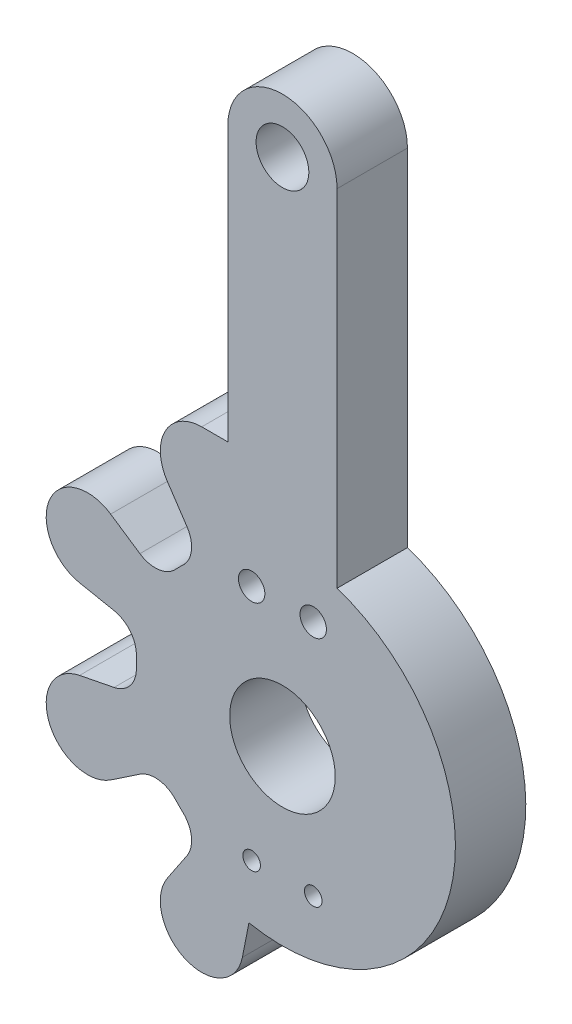
from build123d import *

# Parameters (mm, degrees)
SKETCH1_R           = 1.5
SKETCH1_R_2         = 3
SKETCH1_R_3         = 0.75
SKETCH1_R_4         = 0.5
BOSS_EXTRUDE1_DEPTH = 4


with BuildPart() as part:
    # Sketch1 → Boss-Extrude1 (new body)
    with BuildSketch(Plane.XY):
        with BuildLine():
            Line((16.530619317, 42.42561819), (16.530619317, 22.754982115))
            ThreePointArc((16.530619317, 22.754982115), (22.932240754, 10.915198881), (11.519776525, 3.779592091))
            Line((11.519776525, 3.779592091), (11.147094023, 1.893337277))
            ThreePointArc((11.147094023, 1.893337277), (11.123415667, 1.786594657), (11.094806165, 1.681066709))
            ThreePointArc((11.094806165, 1.681066709), (11.090483266, 1.666641986), (11.086068179, 1.652245212))
            ThreePointArc((11.086068179, 1.652245212), (7.936966432, 0.174837955), (6.754899921, 3.446273846))
            ThreePointArc((6.754899921, 3.446273846), (6.761958039, 3.45957584), (6.769101108, 3.47283241))
            ThreePointArc((6.769101108, 3.47283241), (6.823490663, 3.567681911), (6.882225966, 3.659903468))
            Line((6.882225966, 3.659903468), (7.995950227, 5.322085893))
            ThreePointArc((7.995950227, 5.322085893), (8.251124429, 6.376170558), (7.761765041, 7.344021653))
            ThreePointArc((7.761765041, 7.344021653), (7.549180699, 7.549179572), (7.344022782, 7.761763916))
            ThreePointArc((7.344022782, 7.761763916), (6.376171685, 8.251123307), (5.322087019, 7.995949102))
            Line((5.322087019, 7.995949102), (3.659904592, 6.882224839))
            ThreePointArc((3.659904592, 6.882224839), (3.567683036, 6.823489535), (3.472833536, 6.769099981))
            ThreePointArc((3.472833536, 6.769099981), (3.459576965, 6.761956912), (3.446274971, 6.754898794))
            ThreePointArc((3.446274971, 6.754898794), (0.174839081, 7.936965304), (1.652246338, 11.086067052))
            ThreePointArc((1.652246338, 11.086067052), (1.666643112, 11.090482139), (1.681067834, 11.094805038))
            ThreePointArc((1.681067834, 11.094805038), (1.786595783, 11.12341454), (1.893338403, 11.147092897))
            Line((1.893338403, 11.147092897), (3.856200846, 11.534911383))
            ThreePointArc((3.856200846, 11.534911383), (4.781986668, 12.099826389), (5.120331397, 13.130229803))
            ThreePointArc((5.120331397, 13.130229803), (5.115080125, 13.425618189), (5.120331401, 13.721006575))
            ThreePointArc((5.120331401, 13.721006575), (4.781986671, 14.751409991), (3.856200847, 15.316324996))
            Line((3.856200847, 15.316324996), (1.893338402, 15.704143481))
            ThreePointArc((1.893338402, 15.704143481), (1.786595783, 15.72782184), (1.681067835, 15.756431342))
            ThreePointArc((1.681067835, 15.756431342), (1.666643112, 15.760754241), (1.652246339, 15.765169327))
            ThreePointArc((1.652246339, 15.765169327), (0.174839082, 18.914271075), (3.446274972, 20.096337586))
            ThreePointArc((3.446274972, 20.096337586), (3.459576966, 20.089279467), (3.472833537, 20.082136399))
            ThreePointArc((3.472833537, 20.082136399), (3.567683038, 20.027746844), (3.659904595, 19.969011541))
            Line((3.659904595, 19.969011541), (5.322087019, 18.855287277))
            ThreePointArc((5.322087019, 18.855287277), (6.376171684, 18.600113075), (7.344022779, 19.089472463))
            ThreePointArc((7.344022779, 19.089472463), (7.549180698, 19.302056807), (7.761765042, 19.507214725))
            ThreePointArc((7.761765042, 19.507214725), (8.251124432, 20.475065821), (7.995950227, 21.529150485))
            Line((7.995950227, 21.529150485), (6.882225965, 23.191332912))
            ThreePointArc((6.882225965, 23.191332912), (6.823490661, 23.283554468), (6.769101106, 23.378403968))
            ThreePointArc((6.769101106, 23.378403968), (6.761958038, 23.391660539), (6.754899919, 23.404962533))
            ThreePointArc((6.754899919, 23.404962533), (6.822518946, 25.718097901), (8.837784858, 26.855582349))
            Line((8.837784858, 26.855582349), (10.320619317, 26.855582349))
            Line((10.320619317, 26.855582349), (10.320619317, 42.42561819))
            ThreePointArc((10.320619317, 42.42561819), (13.425619317, 45.53061819), (16.530619317, 42.42561819))
        make_face()
        with Locations((13.425619317, 42.42561819)):
            Circle(SKETCH1_R, mode=Mode.SUBTRACT)
        with Locations((13.425619317, 13.42561819)):
            Circle(SKETCH1_R_2, mode=Mode.SUBTRACT)
        with Locations((11.675619317, 20.42561819)):
            Circle(SKETCH1_R_3, mode=Mode.SUBTRACT)
        with Locations((15.175619317, 20.42561819)):
            Circle(SKETCH1_R_3, mode=Mode.SUBTRACT)
        with Locations((11.675619317, 6.92561819)):
            Circle(SKETCH1_R_4, mode=Mode.SUBTRACT)
        with Locations((15.175619317, 6.92561819)):
            Circle(SKETCH1_R_4, mode=Mode.SUBTRACT)
    extrude(amount=BOSS_EXTRUDE1_DEPTH)


solid = part.part
